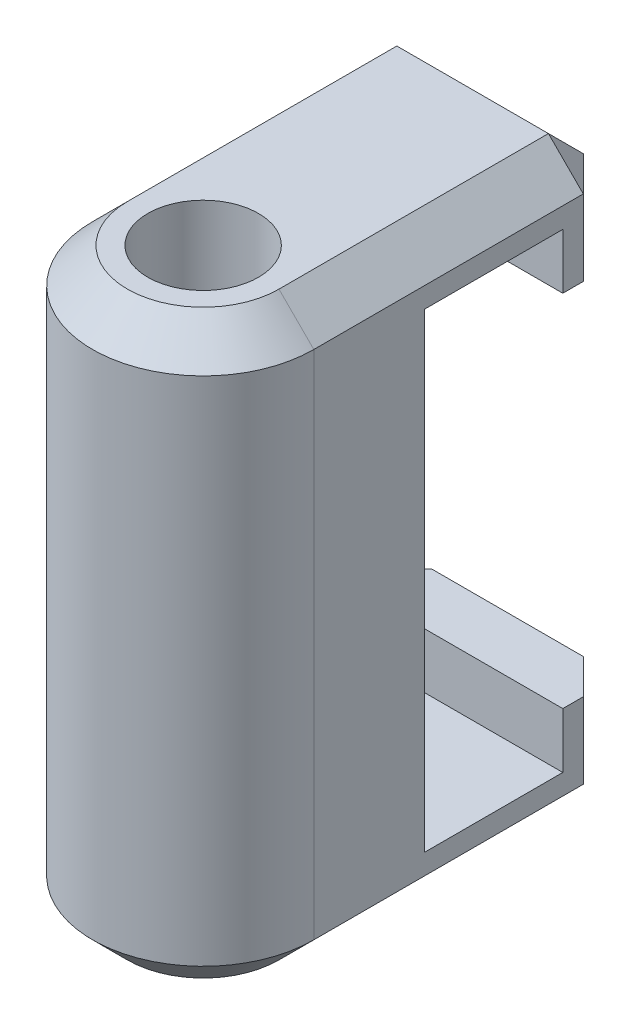
from build123d import *

# Parameters (mm, degrees)
SKETCH1_R           = 1.5875
BOSS_EXTRUDE1_DEPTH = 16.66875
CUT_EXTRUDE1_DEPTH  = 7.35
CHAMFER1_SIZE       = 1


with BuildPart() as part:
    # Sketch1 → Boss-Extrude1 (new body)
    with BuildSketch(Plane(origin=(0, 0, 0), x_dir=(1, 0, 0), z_dir=(0, 1, 0))):
        with BuildLine():
            Line((-3.175, 0), (-3.175, 8.73125))
            Line((-3.175, 8.73125), (3.175, 8.73125))
            Line((3.175, 8.73125), (3.175, 0))
            ThreePointArc((3.175, 0), (0, -3.175), (-3.175, 0))
        make_face()
        Circle(SKETCH1_R, mode=Mode.SUBTRACT)
    extrude(amount=BOSS_EXTRUDE1_DEPTH)

    # Sketch3 → Cut-Extrude1 (cut, through all)
    with BuildSketch(Plane(origin=(3.175, 0, 0), x_dir=(0, 0, -1), z_dir=(1, 0, 0))):
        Polygon((8.73125, 13.49375), (7.14375, 13.49375), (7.14375, 15.08125), (3.175, 15.08125), (3.175, 1.5875), (7.14375, 1.5875), (7.14375, 3.175), (8.73125, 3.175), align=None)
    extrude(amount=-CUT_EXTRUDE1_DEPTH, mode=Mode.SUBTRACT)

    # Chamfer1
    chamfer1_edges = [part.edges().sort_by_distance(p)[0] for p in [
        (0, 16.66875, -8.73125),
        (-3.175, 16.66875, -4.365625),
        (-3.175, 1.5875, -8.73125),
        (3.175, 1.5875, -8.73125),
        (0, 16.66875, 3.175),
        (-3.175, 0, -4.365625),
        (0, 0, -8.73125),
        (3.175, 0, -4.365625),
        (0, 0, 3.175),
        (3.175, 16.66875, -4.365625),
        (-3.175, 15.08125, -8.73125),
        (3.175, 15.08125, -8.73125),
    ]]
    chamfer(chamfer1_edges, length=CHAMFER1_SIZE)


solid = part.part
